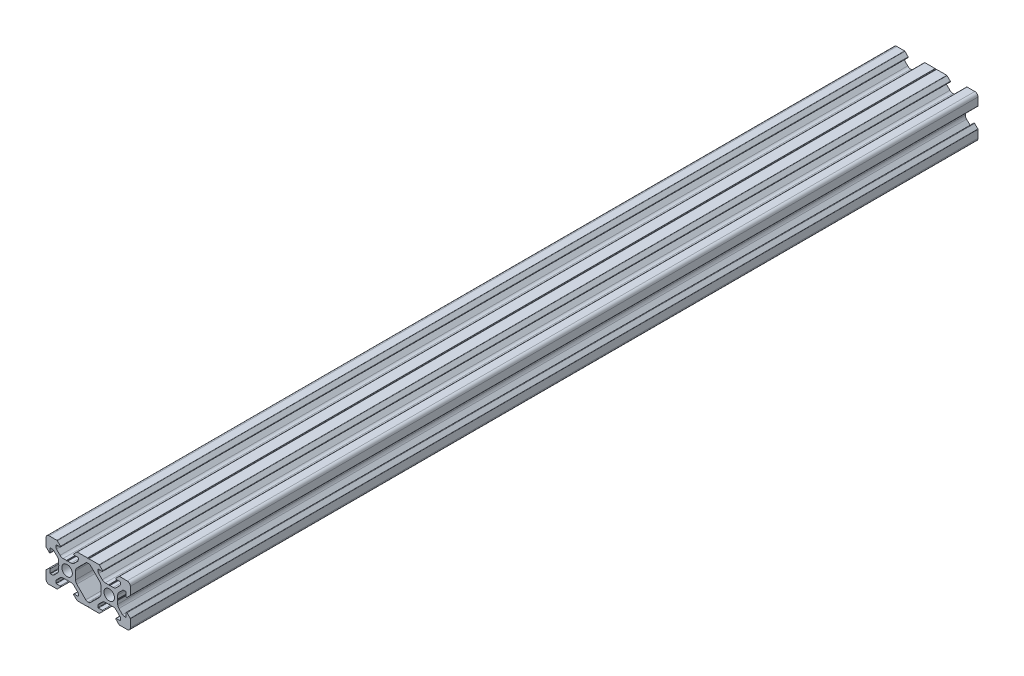
from build123d import *

# Parameters (mm, degrees)
MODEL_R                   = 2.5
BODY_DEPTH                = 402
M6X1_0_TAPPED_HOLE3_D     = 5
M6X1_0_TAPPED_HOLE3_DEPTH = 13.497848452
M6X1_0_TAPPED_HOLE3_TIP   = 1.502151548
M6X1_0_TAPPED_HOLE2_D     = 5
M6X1_0_TAPPED_HOLE2_DEPTH = 13.497848452
M6X1_0_TAPPED_HOLE2_TIP   = 1.502151548


with BuildPart() as part:
    # Model → Body (new body)
    with BuildSketch(Plane.XY):
        with BuildLine():
            Line((0.375693909, 9.662304735), (5.17, 9.662304735))
            ThreePointArc((5.17, 9.662304735), (5.265670858, 9.643274618), (5.346776695, 9.58908143))
            Line((5.346776695, 9.58908143), (6.846776695, 8.08908143))
            ThreePointArc((6.846776695, 8.08908143), (6.900969883, 7.816633877), (6.67, 7.662304735))
            Line((6.67, 7.662304735), (4.9, 7.662304735))
            ThreePointArc((4.9, 7.662304735), (4.758578644, 7.603726091), (4.7, 7.462304735))
            Line((4.7, 7.462304735), (4.7, 6.649310504))
            ThreePointArc((4.7, 6.649310504), (4.776120467, 6.266627071), (4.992893219, 5.942203722))
            Line((4.992893219, 5.942203722), (6.687005769, 4.248091173))
            ThreePointArc((6.687005769, 4.248091173), (7.335852466, 3.81454567), (8.101219331, 3.662304735))
            Line((8.101219331, 3.662304735), (9.662304735, 3.662304735))
            ThreePointArc((9.662304735, 3.662304735), (9.745056471, 3.648211815), (9.818478497, 3.607521938))
            Line((9.818478497, 3.607521938), (10, 3.462304735))
            Line((10, 3.462304735), (10.181521503, 3.607521938))
            ThreePointArc((10.181521503, 3.607521938), (10.254943529, 3.648211815), (10.337695265, 3.662304735))
            Line((10.337695265, 3.662304735), (11.898780669, 3.662304735))
            ThreePointArc((11.898780669, 3.662304735), (12.664147534, 3.81454567), (13.312994231, 4.248091173))
            Line((13.312994231, 4.248091173), (15.007106781, 5.942203722))
            ThreePointArc((15.007106781, 5.942203722), (15.223879533, 6.266627071), (15.3, 6.649310504))
            Line((15.3, 6.649310504), (15.3, 7.462304735))
            ThreePointArc((15.3, 7.462304735), (15.241421356, 7.603726091), (15.1, 7.662304735))
            Line((15.1, 7.662304735), (13.33, 7.662304735))
            ThreePointArc((13.33, 7.662304735), (13.099030117, 7.816633877), (13.153223305, 8.08908143))
            Line((13.153223305, 8.08908143), (14.653223305, 9.58908143))
            ThreePointArc((14.653223305, 9.58908143), (14.734329142, 9.643274618), (14.83, 9.662304735))
            Line((14.83, 9.662304735), (18.5, 9.662304735))
            ThreePointArc((18.5, 9.662304735), (19.560660172, 9.222964907), (20, 8.162304735))
            Line((20, 8.162304735), (20, 4.492304735))
            ThreePointArc((20, 4.492304735), (19.980969883, 4.396633877), (19.926776695, 4.31552804))
            Line((19.926776695, 4.31552804), (18.426776695, 2.81552804))
            ThreePointArc((18.426776695, 2.81552804), (18.154329142, 2.761334852), (18, 2.992304735))
            Line((18, 2.992304735), (18, 4.762304735))
            ThreePointArc((18, 4.762304735), (17.941421356, 4.903726091), (17.8, 4.962304735))
            Line((17.8, 4.962304735), (16.987005769, 4.962304735))
            ThreePointArc((16.987005769, 4.962304735), (16.604322336, 4.886184268), (16.279898987, 4.669411516))
            Line((16.279898987, 4.669411516), (14.585786438, 2.975298967))
            ThreePointArc((14.585786438, 2.975298967), (14.152240935, 2.326452269), (14, 1.561085404))
            Line((14, 1.561085404), (14, 0))
            ThreePointArc((14, 0), (13.98590708, -0.082751735), (13.945217202, -0.156173762))
            Line((13.945217202, -0.156173762), (13.8, -0.337695265))
            Line((13.8, -0.337695265), (13.945217202, -0.519216768))
            ThreePointArc((13.945217202, -0.519216768), (13.98590708, -0.592638794), (14, -0.67539053))
            Line((14, -0.67539053), (14, -2.236475934))
            ThreePointArc((14, -2.236475934), (14.152240935, -3.001842799), (14.585786438, -3.650689496))
            Line((14.585786438, -3.650689496), (16.279898987, -5.344802046))
            ThreePointArc((16.279898987, -5.344802046), (16.604322336, -5.561574797), (16.987005769, -5.637695265))
            Line((16.987005769, -5.637695265), (17.8, -5.637695265))
            ThreePointArc((17.8, -5.637695265), (17.941421356, -5.579116621), (18, -5.437695265))
            Line((18, -5.437695265), (18, -3.667695265))
            ThreePointArc((18, -3.667695265), (18.154329142, -3.436725382), (18.426776695, -3.49091857))
            Line((18.426776695, -3.49091857), (19.926776695, -4.99091857))
            ThreePointArc((19.926776695, -4.99091857), (19.980969883, -5.072024407), (20, -5.167695265))
            Line((20, -5.167695265), (20, -8.837695265))
            ThreePointArc((20, -8.837695265), (19.560660172, -9.898355437), (18.5, -10.337695265))
            Line((18.5, -10.337695265), (14.83, -10.337695265))
            ThreePointArc((14.83, -10.337695265), (14.734329142, -10.318665148), (14.653223305, -10.26447196))
            Line((14.653223305, -10.26447196), (13.153223305, -8.76447196))
            ThreePointArc((13.153223305, -8.76447196), (13.099030117, -8.492024407), (13.33, -8.337695265))
            Line((13.33, -8.337695265), (15.1, -8.337695265))
            ThreePointArc((15.1, -8.337695265), (15.241421356, -8.279116621), (15.3, -8.137695265))
            Line((15.3, -8.137695265), (15.3, -7.324701033))
            ThreePointArc((15.3, -7.324701033), (15.223879533, -6.942017601), (15.007106781, -6.617594252))
            Line((15.007106781, -6.617594252), (13.312994231, -4.923481702))
            ThreePointArc((13.312994231, -4.923481702), (12.664147534, -4.4899362), (11.898780669, -4.337695265))
            Line((11.898780669, -4.337695265), (10.337695265, -4.337695265))
            ThreePointArc((10.337695265, -4.337695265), (10.254943529, -4.323602345), (10.181521503, -4.282912467))
            Line((10.181521503, -4.282912467), (10, -4.137695265))
            Line((10, -4.137695265), (9.818478497, -4.282912467))
            ThreePointArc((9.818478497, -4.282912467), (9.745056471, -4.323602345), (9.662304735, -4.337695265))
            Line((9.662304735, -4.337695265), (8.101219331, -4.337695265))
            ThreePointArc((8.101219331, -4.337695265), (7.335852466, -4.4899362), (6.687005769, -4.923481702))
            Line((6.687005769, -4.923481702), (4.992893219, -6.617594252))
            ThreePointArc((4.992893219, -6.617594252), (4.776120467, -6.942017601), (4.7, -7.324701033))
            Line((4.7, -7.324701033), (4.7, -8.137695265))
            ThreePointArc((4.7, -8.137695265), (4.758578644, -8.279116621), (4.9, -8.337695265))
            Line((4.9, -8.337695265), (6.67, -8.337695265))
            ThreePointArc((6.67, -8.337695265), (6.900969883, -8.492024407), (6.846776695, -8.76447196))
            Line((6.846776695, -8.76447196), (5.346776695, -10.26447196))
            ThreePointArc((5.346776695, -10.26447196), (5.265670858, -10.318665148), (5.17, -10.337695265))
            Line((5.17, -10.337695265), (0.375693909, -10.337695265))
            ThreePointArc((0.375693909, -10.337695265), (0.303247872, -10.326968271), (0.23701886, -10.295707838))
            Line((0.23701886, -10.295707838), (0, -10.137695265))
            Line((0, -10.137695265), (-0.23701886, -10.295707838))
            ThreePointArc((-0.23701886, -10.295707838), (-0.303247872, -10.326968271), (-0.375693909, -10.337695265))
            Line((-0.375693909, -10.337695265), (-5.17, -10.337695265))
            ThreePointArc((-5.17, -10.337695265), (-5.265670858, -10.318665148), (-5.346776695, -10.26447196))
            Line((-5.346776695, -10.26447196), (-6.846776695, -8.76447196))
            ThreePointArc((-6.846776695, -8.76447196), (-6.900969883, -8.492024407), (-6.67, -8.337695265))
            Line((-6.67, -8.337695265), (-4.9, -8.337695265))
            ThreePointArc((-4.9, -8.337695265), (-4.758578644, -8.279116621), (-4.7, -8.137695265))
            Line((-4.7, -8.137695265), (-4.7, -7.324701033))
            ThreePointArc((-4.7, -7.324701033), (-4.776120467, -6.942017601), (-4.992893219, -6.617594252))
            Line((-4.992893219, -6.617594252), (-6.687005769, -4.923481702))
            ThreePointArc((-6.687005769, -4.923481702), (-7.335852466, -4.4899362), (-8.101219331, -4.337695265))
            Line((-8.101219331, -4.337695265), (-9.662304735, -4.337695265))
            ThreePointArc((-9.662304735, -4.337695265), (-9.745056471, -4.323602345), (-9.818478497, -4.282912467))
            Line((-9.818478497, -4.282912467), (-10, -4.137695265))
            Line((-10, -4.137695265), (-10.181521503, -4.282912467))
            ThreePointArc((-10.181521503, -4.282912467), (-10.254943529, -4.323602345), (-10.337695265, -4.337695265))
            Line((-10.337695265, -4.337695265), (-11.898780669, -4.337695265))
            ThreePointArc((-11.898780669, -4.337695265), (-12.664147534, -4.4899362), (-13.312994231, -4.923481702))
            Line((-13.312994231, -4.923481702), (-15.007106781, -6.617594252))
            ThreePointArc((-15.007106781, -6.617594252), (-15.223879533, -6.942017601), (-15.3, -7.324701033))
            Line((-15.3, -7.324701033), (-15.3, -8.137695265))
            ThreePointArc((-15.3, -8.137695265), (-15.241421356, -8.279116621), (-15.1, -8.337695265))
            Line((-15.1, -8.337695265), (-13.33, -8.337695265))
            ThreePointArc((-13.33, -8.337695265), (-13.099030117, -8.492024407), (-13.153223305, -8.76447196))
            Line((-13.153223305, -8.76447196), (-14.653223305, -10.26447196))
            ThreePointArc((-14.653223305, -10.26447196), (-14.734329142, -10.318665148), (-14.83, -10.337695265))
            Line((-14.83, -10.337695265), (-18.5, -10.337695265))
            ThreePointArc((-18.5, -10.337695265), (-19.560660172, -9.898355437), (-20, -8.837695265))
            Line((-20, -8.837695265), (-20, -5.167695265))
            ThreePointArc((-20, -5.167695265), (-19.980969883, -5.072024407), (-19.926776695, -4.99091857))
            Line((-19.926776695, -4.99091857), (-18.426776695, -3.49091857))
            ThreePointArc((-18.426776695, -3.49091857), (-18.154329142, -3.436725382), (-18, -3.667695265))
            Line((-18, -3.667695265), (-18, -5.437695265))
            ThreePointArc((-18, -5.437695265), (-17.941421356, -5.579116621), (-17.8, -5.637695265))
            Line((-17.8, -5.637695265), (-16.987005769, -5.637695265))
            ThreePointArc((-16.987005769, -5.637695265), (-16.604322336, -5.561574797), (-16.279898987, -5.344802046))
            Line((-16.279898987, -5.344802046), (-14.585786438, -3.650689496))
            ThreePointArc((-14.585786438, -3.650689496), (-14.152240935, -3.001842799), (-14, -2.236475934))
            Line((-14, -2.236475934), (-14, -0.67539053))
            ThreePointArc((-14, -0.67539053), (-13.98590708, -0.592638794), (-13.945217202, -0.519216768))
            Line((-13.945217202, -0.519216768), (-13.8, -0.337695265))
            Line((-13.8, -0.337695265), (-13.945217202, -0.156173762))
            ThreePointArc((-13.945217202, -0.156173762), (-13.98590708, -0.082751735), (-14, 0))
            Line((-14, 0), (-14, 1.561085404))
            ThreePointArc((-14, 1.561085404), (-14.152240935, 2.326452269), (-14.585786438, 2.975298967))
            Line((-14.585786438, 2.975298967), (-16.279898987, 4.669411516))
            ThreePointArc((-16.279898987, 4.669411516), (-16.604322336, 4.886184268), (-16.987005769, 4.962304735))
            Line((-16.987005769, 4.962304735), (-17.8, 4.962304735))
            ThreePointArc((-17.8, 4.962304735), (-17.941421356, 4.903726091), (-18, 4.762304735))
            Line((-18, 4.762304735), (-18, 2.992304735))
            ThreePointArc((-18, 2.992304735), (-18.154329142, 2.761334852), (-18.426776695, 2.81552804))
            Line((-18.426776695, 2.81552804), (-19.926776695, 4.31552804))
            ThreePointArc((-19.926776695, 4.31552804), (-19.980969883, 4.396633877), (-20, 4.492304735))
            Line((-20, 4.492304735), (-20, 8.162304735))
            ThreePointArc((-20, 8.162304735), (-19.560660172, 9.222964907), (-18.5, 9.662304735))
            Line((-18.5, 9.662304735), (-14.83, 9.662304735))
            ThreePointArc((-14.83, 9.662304735), (-14.734329142, 9.643274618), (-14.653223305, 9.58908143))
            Line((-14.653223305, 9.58908143), (-13.153223305, 8.08908143))
            ThreePointArc((-13.153223305, 8.08908143), (-13.099030117, 7.816633877), (-13.33, 7.662304735))
            Line((-13.33, 7.662304735), (-15.1, 7.662304735))
            ThreePointArc((-15.1, 7.662304735), (-15.241421356, 7.603726091), (-15.3, 7.462304735))
            Line((-15.3, 7.462304735), (-15.3, 6.649310504))
            ThreePointArc((-15.3, 6.649310504), (-15.223879533, 6.266627071), (-15.007106781, 5.942203722))
            Line((-15.007106781, 5.942203722), (-13.312994231, 4.248091173))
            ThreePointArc((-13.312994231, 4.248091173), (-12.664147534, 3.81454567), (-11.898780669, 3.662304735))
            Line((-11.898780669, 3.662304735), (-10.337695265, 3.662304735))
            ThreePointArc((-10.337695265, 3.662304735), (-10.254943529, 3.648211815), (-10.181521503, 3.607521938))
            Line((-10.181521503, 3.607521938), (-10, 3.462304735))
            Line((-10, 3.462304735), (-9.818478497, 3.607521938))
            ThreePointArc((-9.818478497, 3.607521938), (-9.745056471, 3.648211815), (-9.662304735, 3.662304735))
            Line((-9.662304735, 3.662304735), (-8.101219331, 3.662304735))
            ThreePointArc((-8.101219331, 3.662304735), (-7.335852466, 3.81454567), (-6.687005769, 4.248091173))
            Line((-6.687005769, 4.248091173), (-4.992893219, 5.942203722))
            ThreePointArc((-4.992893219, 5.942203722), (-4.776120467, 6.266627071), (-4.7, 6.649310504))
            Line((-4.7, 6.649310504), (-4.7, 7.462304735))
            ThreePointArc((-4.7, 7.462304735), (-4.758578644, 7.603726091), (-4.9, 7.662304735))
            Line((-4.9, 7.662304735), (-6.67, 7.662304735))
            ThreePointArc((-6.67, 7.662304735), (-6.900969883, 7.816633877), (-6.846776695, 8.08908143))
            Line((-6.846776695, 8.08908143), (-5.346776695, 9.58908143))
            ThreePointArc((-5.346776695, 9.58908143), (-5.265670858, 9.643274618), (-5.17, 9.662304735))
            Line((-5.17, 9.662304735), (-0.375693909, 9.662304735))
            ThreePointArc((-0.375693909, 9.662304735), (-0.303247872, 9.651577742), (-0.23701886, 9.620317309))
            Line((-0.23701886, 9.620317309), (0, 9.462304735))
            Line((0, 9.462304735), (0.23701886, 9.620317309))
            ThreePointArc((0.23701886, 9.620317309), (0.303247872, 9.651577742), (0.375693909, 9.662304735))
        make_face()
        with Locations((10, -0.337695265)):
            Circle(MODEL_R, mode=Mode.SUBTRACT)
        with Locations((-10, -0.337695265)):
            Circle(MODEL_R, mode=Mode.SUBTRACT)
        with BuildLine():
            Line((-5.414213562, 2.975298967), (-1.1372583, 7.252254229))
            ThreePointArc((-1.1372583, 7.252254229), (-0.683065612, 7.555736081), (-0.147308807, 7.662304735))
            Line((-0.147308807, 7.662304735), (0.147308807, 7.662304735))
            ThreePointArc((0.147308807, 7.662304735), (0.683065612, 7.555736081), (1.1372583, 7.252254229))
            Line((1.1372583, 7.252254229), (5.414213562, 2.975298967))
            ThreePointArc((5.414213562, 2.975298967), (5.847759065, 2.326452269), (6, 1.561085404))
            Line((6, 1.561085404), (6, -2.236475934))
            ThreePointArc((6, -2.236475934), (5.847759065, -3.001842799), (5.414213562, -3.650689496))
            Line((5.414213562, -3.650689496), (1.1372583, -7.927644759))
            ThreePointArc((1.1372583, -7.927644759), (0.683065612, -8.23112661), (0.147308807, -8.337695265))
            Line((0.147308807, -8.337695265), (-0.147308807, -8.337695265))
            ThreePointArc((-0.147308807, -8.337695265), (-0.683065612, -8.23112661), (-1.1372583, -7.927644759))
            Line((-1.1372583, -7.927644759), (-5.414213562, -3.650689496))
            ThreePointArc((-5.414213562, -3.650689496), (-5.847759065, -3.001842799), (-6, -2.236475934))
            Line((-6, -2.236475934), (-6, 1.561085404))
            ThreePointArc((-6, 1.561085404), (-5.847759065, 2.326452269), (-5.414213562, 2.975298967))
        make_face(mode=Mode.SUBTRACT)
    extrude(amount=BODY_DEPTH)

    # M6x1.0 Tapped Hole3
    with Locations(Plane.XY.offset(402)):
        with Locations((-10, -0.337695265), (10, -0.337695265)):
            Hole(M6X1_0_TAPPED_HOLE3_D / 2, depth=M6X1_0_TAPPED_HOLE3_DEPTH)
            with Locations((0, 0, -(M6X1_0_TAPPED_HOLE3_DEPTH + M6X1_0_TAPPED_HOLE3_TIP / 2))):  # 118° drill point
                Cone(0, M6X1_0_TAPPED_HOLE3_D / 2, M6X1_0_TAPPED_HOLE3_TIP, mode=Mode.SUBTRACT)

    # M6x1.0 Tapped Hole2
    with Locations(Plane(origin=(0, 0, 0), x_dir=(-1, 0, 0), z_dir=(0, 0, -1))):
        with Locations((-10, -0.337695265), (10, -0.337695265)):
            Hole(M6X1_0_TAPPED_HOLE2_D / 2, depth=M6X1_0_TAPPED_HOLE2_DEPTH)
            with Locations((0, 0, -(M6X1_0_TAPPED_HOLE2_DEPTH + M6X1_0_TAPPED_HOLE2_TIP / 2))):  # 118° drill point
                Cone(0, M6X1_0_TAPPED_HOLE2_D / 2, M6X1_0_TAPPED_HOLE2_TIP, mode=Mode.SUBTRACT)


solid = part.part
